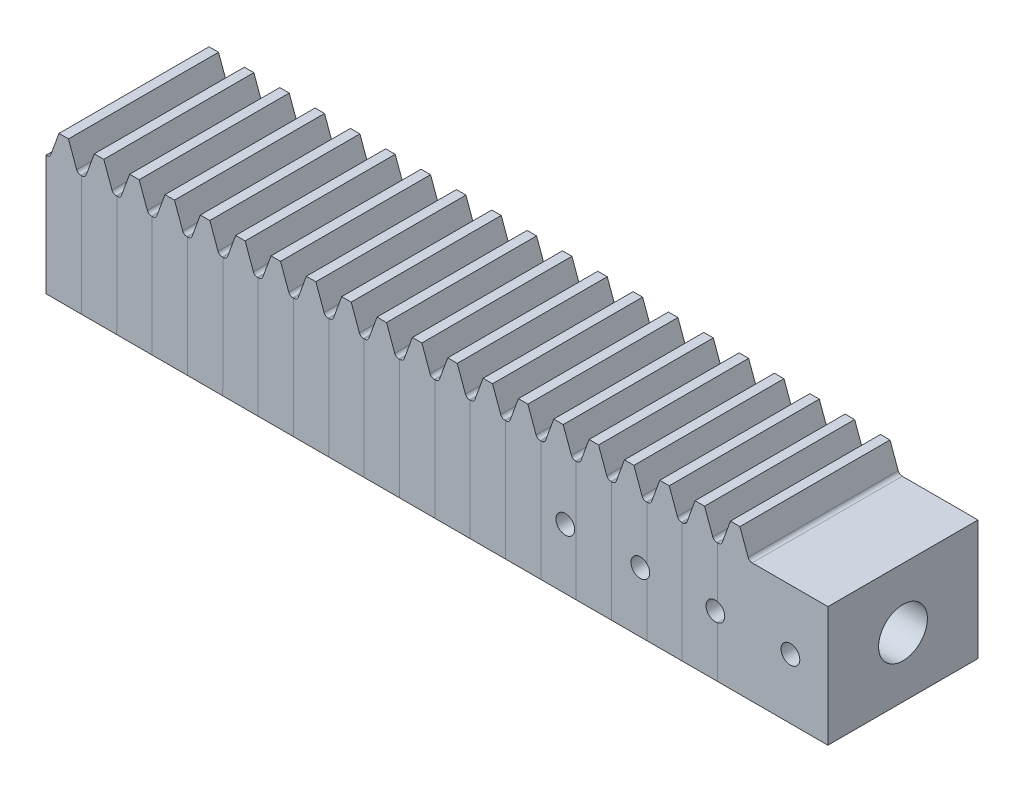
from build123d import *

# Parameters (mm, degrees)
MAIN_DEPTH          = 20
SKETCH2_W           = 4.721082869
SKETCH2_H           = 16
SUPPORT_DEPTH       = 20
SKETCH3_R           = 6.15
AXISHOLE_DEPTH      = 5.721082869
FILLET1_R           = 0.57
LPATTERN2_COUNT     = 20
LPATTERN2_PITCH     = 4.71
SKETCH4_W           = 20
SKETCH4_H           = 16
SKETCH4_R           = 3.25
BOSS_EXTRUDE1_DEPTH = 10
SKETCH5_R           = 1.25
CUT_EXTRUDE1_DEPTH  = 21
LPATTERN3_COUNT     = 4
LPATTERN3_PITCH     = 10


with BuildPart() as part:
    # Sketch1 → Main (new body)
    with BuildSketch(Plane.XY):
        Polygon((-3.721082869, 0), (-2.492683328, 3.375), (-1.228399541, 3.375), (0, 0), align=None)
    extrude(amount=MAIN_DEPTH)

    # Sketch2 → Support (add)
    with BuildSketch(Plane.XY.offset(20)):
        with Locations((-1.860541434, -8)):
            Rectangle(SKETCH2_W, SKETCH2_H)
    extrude(amount=-SUPPORT_DEPTH)

    # Sketch3 → AxisHole (cut, through all)
    with BuildSketch(Plane.ZY.offset(4.221082869)):
        with Locations((10, -8)):
            Circle(SKETCH3_R)
    extrude(amount=-AXISHOLE_DEPTH, mode=Mode.SUBTRACT)

    # Fillet1
    fillet1_edges = [part.edges().sort_by_distance(p)[0] for p in [
        (-3.721082869, 0, 10),
        (0, 0, 10),
    ]]
    fillet(fillet1_edges, radius=FILLET1_R)


with BuildPart() as lpattern2_1:
    # LPattern2: pattern copy
    add(part.part.moved(Location(Vector(-1, 0, 0) * (1 * LPATTERN2_PITCH))))


with BuildPart() as lpattern2_2:
    # LPattern2: pattern copy
    add(part.part.moved(Location(Vector(-1, 0, 0) * (2 * LPATTERN2_PITCH))))


with BuildPart() as lpattern2_3:
    # LPattern2: pattern copy
    add(part.part.moved(Location(Vector(-1, 0, 0) * (3 * LPATTERN2_PITCH))))


with BuildPart() as lpattern2_4:
    # LPattern2: pattern copy
    add(part.part.moved(Location(Vector(-1, 0, 0) * (4 * LPATTERN2_PITCH))))


with BuildPart() as lpattern2_5:
    # LPattern2: pattern copy
    add(part.part.moved(Location(Vector(-1, 0, 0) * (5 * LPATTERN2_PITCH))))


with BuildPart() as lpattern2_6:
    # LPattern2: pattern copy
    add(part.part.moved(Location(Vector(-1, 0, 0) * (6 * LPATTERN2_PITCH))))


with BuildPart() as lpattern2_7:
    # LPattern2: pattern copy
    add(part.part.moved(Location(Vector(-1, 0, 0) * (7 * LPATTERN2_PITCH))))


with BuildPart() as lpattern2_8:
    # LPattern2: pattern copy
    add(part.part.moved(Location(Vector(-1, 0, 0) * (8 * LPATTERN2_PITCH))))


with BuildPart() as lpattern2_9:
    # LPattern2: pattern copy
    add(part.part.moved(Location(Vector(-1, 0, 0) * (9 * LPATTERN2_PITCH))))


with BuildPart() as lpattern2_10:
    # LPattern2: pattern copy
    add(part.part.moved(Location(Vector(-1, 0, 0) * (10 * LPATTERN2_PITCH))))


with BuildPart() as lpattern2_11:
    # LPattern2: pattern copy
    add(part.part.moved(Location(Vector(-1, 0, 0) * (11 * LPATTERN2_PITCH))))


with BuildPart() as lpattern2_12:
    # LPattern2: pattern copy
    add(part.part.moved(Location(Vector(-1, 0, 0) * (12 * LPATTERN2_PITCH))))


with BuildPart() as lpattern2_13:
    # LPattern2: pattern copy
    add(part.part.moved(Location(Vector(-1, 0, 0) * (13 * LPATTERN2_PITCH))))


with BuildPart() as lpattern2_14:
    # LPattern2: pattern copy
    add(part.part.moved(Location(Vector(-1, 0, 0) * (14 * LPATTERN2_PITCH))))


with BuildPart() as lpattern2_15:
    # LPattern2: pattern copy
    add(part.part.moved(Location(Vector(-1, 0, 0) * (15 * LPATTERN2_PITCH))))


with BuildPart() as lpattern2_16:
    # LPattern2: pattern copy
    add(part.part.moved(Location(Vector(-1, 0, 0) * (16 * LPATTERN2_PITCH))))


with BuildPart() as lpattern2_17:
    # LPattern2: pattern copy
    add(part.part.moved(Location(Vector(-1, 0, 0) * (17 * LPATTERN2_PITCH))))


with BuildPart() as lpattern2_18:
    # LPattern2: pattern copy
    add(part.part.moved(Location(Vector(-1, 0, 0) * (18 * LPATTERN2_PITCH))))


with BuildPart() as lpattern2_19:
    # LPattern2: pattern copy
    add(part.part.moved(Location(Vector(-1, 0, 0) * (19 * LPATTERN2_PITCH))))


with BuildPart() as part_1:
    add(part.part)

    # Sketch4 → Boss-Extrude1 (add)
    with BuildSketch(Plane(origin=(0.5, 0, 0), x_dir=(0, 0, -1), z_dir=(1, 0, 0))):
        with Locations((-10, -8)):
            Rectangle(SKETCH4_W, SKETCH4_H)
        with Locations((-10, -8)):
            Circle(SKETCH4_R, mode=Mode.SUBTRACT)
    extrude(amount=BOSS_EXTRUDE1_DEPTH)

    # Sketch5 → Cut-Extrude1 (cut, through all)
    with BuildSketch(Plane.XY.offset(20)):
        with Locations((5.5, -8)):
            Circle(SKETCH5_R)
    cut_extrude1 = extrude(amount=-CUT_EXTRUDE1_DEPTH, mode=Mode.SUBTRACT)


with BuildPart() as lpattern3_tool:
    # LPattern3: Cut-Extrude1 ×4
    with Locations(*[(-i * LPATTERN3_PITCH, 0, 0) for i in range(1, LPATTERN3_COUNT)]):
        add(cut_extrude1)


with BuildPart() as part_2:
    add(part_1.part)

    # LPattern3: cut by lpattern3_tool
    add(lpattern3_tool.part, mode=Mode.SUBTRACT)


with BuildPart() as lpattern2_1_1:
    add(lpattern2_1.part)

    # LPattern3: cut by lpattern3_tool
    add(lpattern3_tool.part, mode=Mode.SUBTRACT)


with BuildPart() as lpattern2_2_1:
    add(lpattern2_2.part)

    # LPattern3: cut by lpattern3_tool
    add(lpattern3_tool.part, mode=Mode.SUBTRACT)


with BuildPart() as lpattern2_3_1:
    add(lpattern2_3.part)

    # LPattern3: cut by lpattern3_tool
    add(lpattern3_tool.part, mode=Mode.SUBTRACT)


with BuildPart() as lpattern2_5_1:
    add(lpattern2_5.part)

    # LPattern3: cut by lpattern3_tool
    add(lpattern3_tool.part, mode=Mode.SUBTRACT)


solid = Compound([lpattern2_4.part, lpattern2_6.part, lpattern2_7.part, lpattern2_8.part, lpattern2_9.part, lpattern2_10.part, lpattern2_11.part, lpattern2_12.part, lpattern2_13.part, lpattern2_14.part, lpattern2_15.part, lpattern2_16.part, lpattern2_17.part, lpattern2_18.part, lpattern2_19.part, part_2.part, lpattern2_1_1.part, lpattern2_2_1.part, lpattern2_3_1.part, lpattern2_5_1.part])
